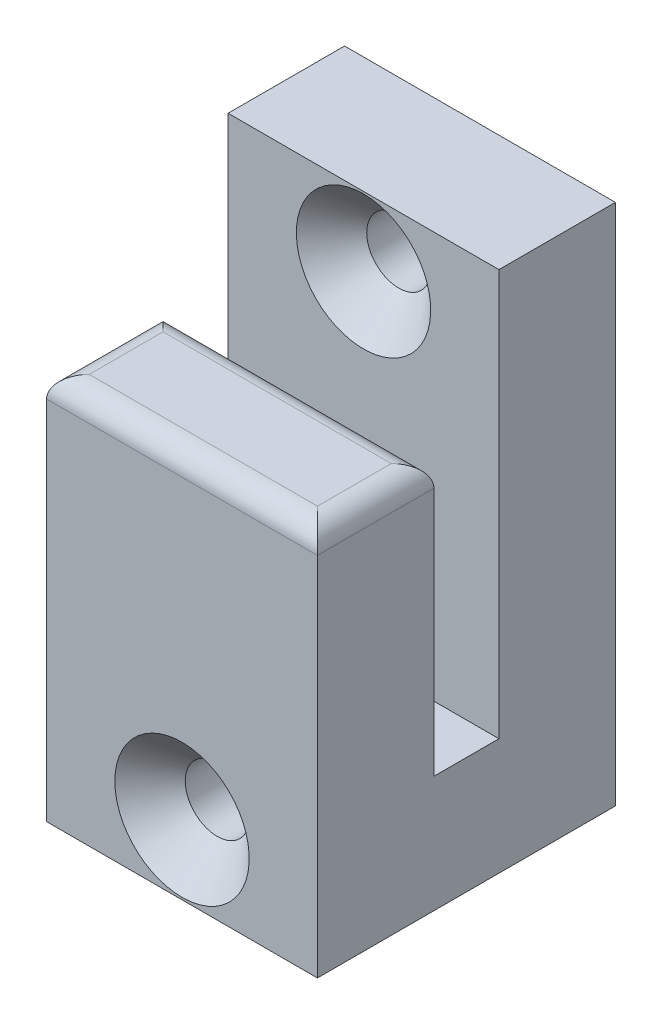
from build123d import *

# Parameters (mm, degrees)
BOSS_EXTRUDE1_DEPTH = 25.4
SKETCH2_R           = 3
CUT_EXTRUDE1_DEPTH  = 28.944
CHAMFER1_SIZE       = 3.3
FILLET1_R           = 2


with BuildPart() as part:
    # Sketch1 → Boss-Extrude1 (new body)
    with BuildSketch(Plane(origin=(0, 0, 0), x_dir=(0, 0, -1), z_dir=(1, 0, 0))):
        Polygon((-0.970833333, 15.458470238), (-11.892833333, 15.458470238), (-11.892833333, -20.863529762), (16.051166667, -20.863529762), (16.051166667, 28.158470238), (5.129166667, 28.158470238), (5.129166667, -9.941529762), (-0.970833333, -9.941529762), align=None)
    extrude(amount=BOSS_EXTRUDE1_DEPTH)

    # Sketch2 → Cut-Extrude1 (cut, through all)
    with BuildSketch(Plane(origin=(0, 0, -16.051166667), x_dir=(-1, 0, 0), z_dir=(0, 0, -1))):
        with Locations((-12.7, 21.658470238)):
            Circle(SKETCH2_R)
        with Locations((-12.7, -14.363529762)):
            Circle(SKETCH2_R)
    extrude(amount=-CUT_EXTRUDE1_DEPTH, mode=Mode.SUBTRACT)

    # Chamfer1
    chamfer1_edges = [part.edges().sort_by_distance(p)[0] for p in [
        (15.7, 21.658470238, -5.129166667),
        (15.7, -14.363529762, 11.892833333),
    ]]
    chamfer(chamfer1_edges, length=CHAMFER1_SIZE)

    # Fillet1
    fillet1_edges = [part.edges().sort_by_distance(p)[0] for p in [
        (12.7, 15.458470238, 11.892833333),
        (12.7, 15.458470238, 0.970833333),
        (25.4, 15.458470238, 6.431833333),
        (0, 15.458470238, 6.431833333),
    ]]
    fillet(fillet1_edges, radius=FILLET1_R)


solid = part.part
